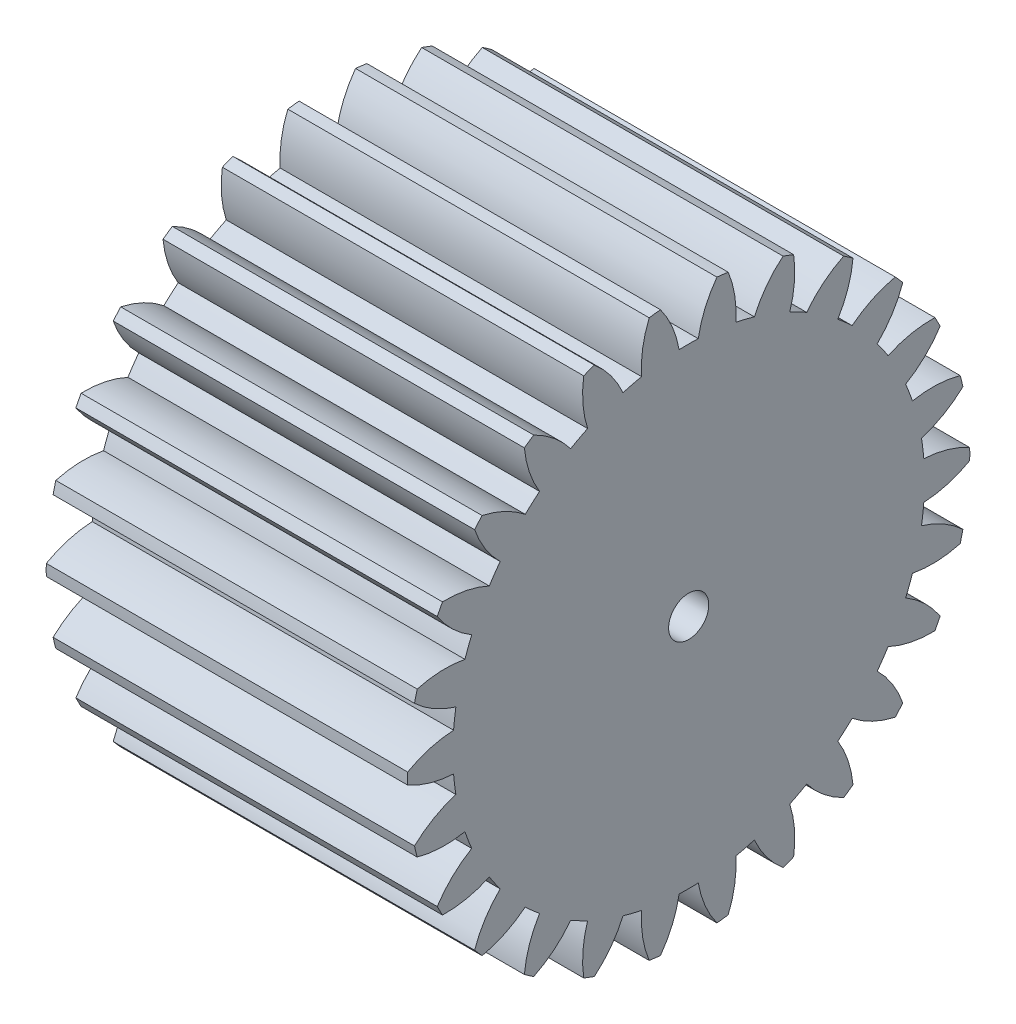
from build123d import *

# Parameters (mm, degrees)
BASPROSKE_W     = 9
BASPROSKE_H     = 7
TOOTHCUT_DEPTH  = 14.37908816
TEETHCUTS_COUNT = 26
TEETHCUTS_ANGLE = 346.153846154
BORSKE_R        = 0.5
BORE_DEPTH      = 50.0000508


with BuildPart() as part:
    # BasProSke → Base-Revolve (revolve)
    with BuildSketch(Plane(origin=(0, 0, 0), x_dir=(1, 0, 0), z_dir=(0, 1, 0)), mode=Mode.PRIVATE) as base_revolve_sk:
        with Locations((4.5, 3.5)):
            Rectangle(BASPROSKE_W, BASPROSKE_H)
    revolve(base_revolve_sk.sketch.rotate(Axis((-10, 0, 0), (1, 0, 0)), 180), axis=Axis((-10, 0, 0), (1, 0, 0)))

    # TooCutSke → ToothCut (cut, through all)
    with BuildSketch(Plane(origin=(0, 0, 0), x_dir=(0, 0, -1), z_dir=(1, 0, 0))):
        with BuildLine():
            ThreePointArc((0.238396934, 5.869160323), (0, 5.874), (-0.238396934, 5.869160323))
            ThreePointArc((-0.238396934, 5.869160323), (-0.413148985, 6.457408383), (-0.720902762, 6.988314845))
            ThreePointArc((-0.720902762, 6.988314845), (0, 7.0254), (0.720902762, 6.988314845))
            ThreePointArc((0.720902762, 6.988314845), (0.413148985, 6.457408383), (0.238396934, 5.869160323))
        make_face()
    toothcut = extrude(amount=TOOTHCUT_DEPTH, mode=Mode.SUBTRACT)

    # TeethCuts: ToothCut ×26 about axis
    teethcuts_axis = Axis((-10, 0, 0), (1, 0, 0))
    for i in range(1, TEETHCUTS_COUNT):
        add(toothcut.rotate(teethcuts_axis, i * TEETHCUTS_ANGLE / (TEETHCUTS_COUNT - 1)), mode=Mode.SUBTRACT)

    # BorSke → Bore (cut, symmetric)
    with BuildSketch(Plane(origin=(0, 0, 0), x_dir=(0, 0, -1), z_dir=(1, 0, 0))):
        with Locations(Location((0, 0, 0), (0, 0, 180))):
            Circle(BORSKE_R)
    extrude(amount=BORE_DEPTH, both=True, mode=Mode.SUBTRACT)


solid = part.part
